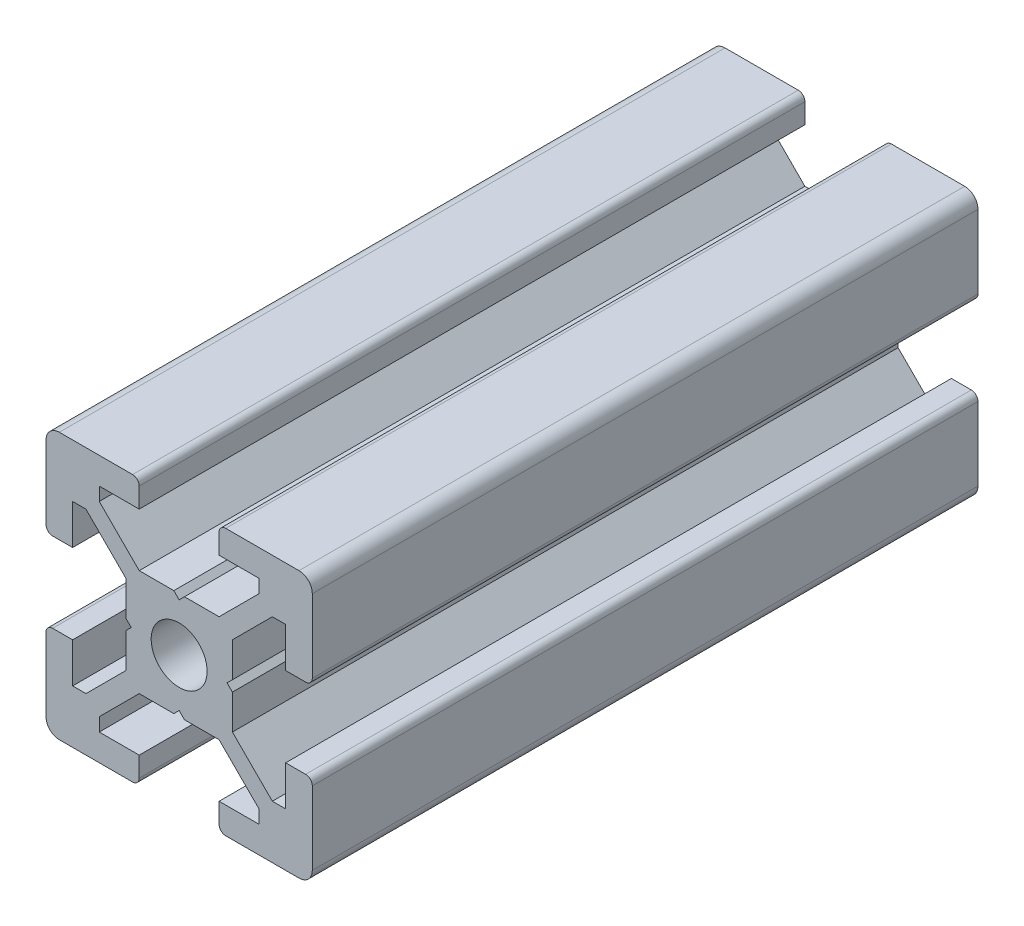
from build123d import *

# Parameters (mm, degrees)
SCHIZZO1_R                   = 2.1
ESTRUSIONE_ESTRUSIONE1_DEPTH = 50


with BuildPart() as part:
    # Schizzo1 → Estrusione-Estrusione1 (new body)
    with BuildSketch(Plane.XY):
        with BuildLine():
            Line((-3.6, 0), (-4, 0.4))
            Line((-4, 0.4), (-4, 3))
            Line((-4, 3), (-7, 6))
            Line((-7, 6), (-8, 6))
            Line((-8, 6), (-8, 3))
            Line((-8, 3), (-9.5, 3))
            ThreePointArc((-9.5, 3), (-9.853553391, 3.146446609), (-10, 3.5))
            Line((-10, 3.5), (-10, 9))
            ThreePointArc((-10, 9), (-9.707106781, 9.707106781), (-9, 10))
            Line((-9, 10), (-3.5, 10))
            ThreePointArc((-3.5, 10), (-3.146446609, 9.853553391), (-3, 9.5))
            Line((-3, 9.5), (-3, 8))
            Line((-3, 8), (-6, 8))
            Line((-6, 8), (-6, 7))
            Line((-6, 7), (-3, 4))
            Line((-3, 4), (-0.4, 4))
            Line((-0.4, 4), (0, 3.6))
            Line((0, 3.6), (0.4, 4))
            Line((0.4, 4), (3, 4))
            Line((3, 4), (6, 7))
            Line((6, 7), (6, 8))
            Line((6, 8), (3, 8))
            Line((3, 8), (3, 9.5))
            ThreePointArc((3, 9.5), (3.146446609, 9.853553391), (3.5, 10))
            Line((3.5, 10), (9, 10))
            ThreePointArc((9, 10), (9.707106781, 9.707106781), (10, 9))
            Line((10, 9), (10, 3.5))
            ThreePointArc((10, 3.5), (9.853553391, 3.146446609), (9.5, 3))
            Line((9.5, 3), (8, 3))
            Line((8, 3), (8, 6))
            Line((8, 6), (7, 6))
            Line((7, 6), (4, 3))
            Line((4, 3), (4, 0.4))
            Line((4, 0.4), (3.6, 0))
            Line((3.6, 0), (4, -0.4))
            Line((4, -0.4), (4, -3))
            Line((4, -3), (7, -6))
            Line((7, -6), (8, -6))
            Line((8, -6), (8, -3))
            Line((8, -3), (9.5, -3))
            ThreePointArc((9.5, -3), (9.853553391, -3.146446609), (10, -3.5))
            Line((10, -3.5), (10, -9))
            ThreePointArc((10, -9), (9.707106781, -9.707106781), (9, -10))
            Line((9, -10), (3.5, -10))
            ThreePointArc((3.5, -10), (3.146446609, -9.853553391), (3, -9.5))
            Line((3, -9.5), (3, -8))
            Line((3, -8), (6, -8))
            Line((6, -8), (6, -7))
            Line((6, -7), (3, -4))
            Line((3, -4), (0.4, -4))
            Line((0.4, -4), (0, -3.6))
            Line((0, -3.6), (-0.4, -4))
            Line((-0.4, -4), (-3, -4))
            Line((-3, -4), (-6, -7))
            Line((-6, -7), (-6, -8))
            Line((-6, -8), (-3, -8))
            Line((-3, -8), (-3, -9.5))
            ThreePointArc((-3, -9.5), (-3.146446609, -9.853553391), (-3.5, -10))
            Line((-3.5, -10), (-9, -10))
            ThreePointArc((-9, -10), (-9.707106781, -9.707106781), (-10, -9))
            Line((-10, -9), (-10, -3.5))
            ThreePointArc((-10, -3.5), (-9.853553391, -3.146446609), (-9.5, -3))
            Line((-9.5, -3), (-8, -3))
            Line((-8, -3), (-8, -6))
            Line((-8, -6), (-7, -6))
            Line((-7, -6), (-4, -3))
            Line((-4, -3), (-4, -0.4))
            Line((-4, -0.4), (-3.6, 0))
        make_face()
        Circle(SCHIZZO1_R, mode=Mode.SUBTRACT)
    extrude(amount=ESTRUSIONE_ESTRUSIONE1_DEPTH)


solid = part.part
